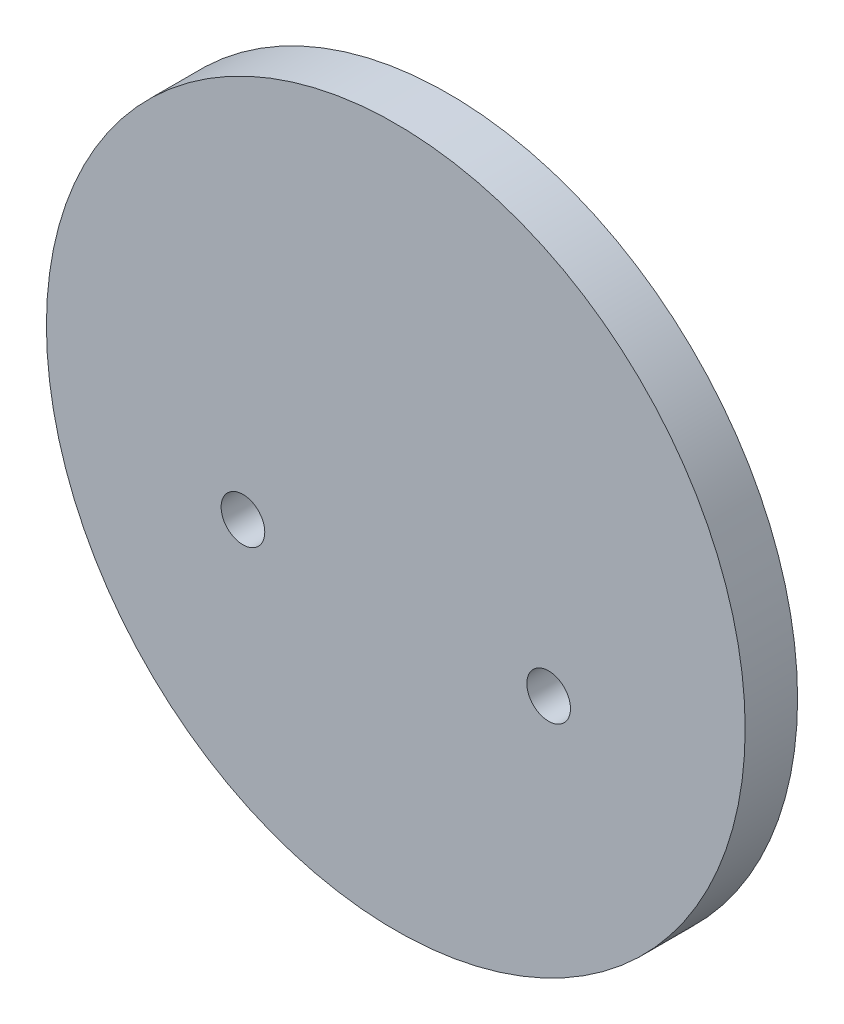
from build123d import *

# Parameters (mm, degrees)
SKETCH3_R           = 40
BOSS_EXTRUDE1_DEPTH = 6
SKETCH4_R           = 2.1
CUT_EXTRUDE1_DEPTH  = 57.885850613
SKETCH5_R           = 5
CUT_EXTRUDE2_DEPTH  = 1.5
MOVE_FACE1_BY       = 0.4
MOVE_FACE1_2_BY     = 0.4


with BuildPart() as part:
    # Sketch3 → Boss-Extrude1 (new body)
    with BuildSketch(Plane.XY):
        Circle(SKETCH3_R)
    extrude(amount=BOSS_EXTRUDE1_DEPTH)

    # Sketch4 → Cut-Extrude1 (cut, through all)
    with BuildSketch(Plane.XY.offset(6)):
        with Locations((-17.5, -8)):
            Circle(SKETCH4_R)
        with Locations((17.5, -8)):
            Circle(SKETCH4_R)
    extrude(amount=-CUT_EXTRUDE1_DEPTH, mode=Mode.SUBTRACT)

    # Sketch5 → Cut-Extrude2 (cut)
    with BuildSketch(Plane(origin=(0, 0, 0), x_dir=(-1, 0, 0), z_dir=(0, 0, -1))):
        with Locations((-17.5, -8)):
            Circle(SKETCH5_R)
        with Locations((17.5, -8)):
            Circle(SKETCH5_R)
    extrude(amount=-CUT_EXTRUDE2_DEPTH, mode=Mode.SUBTRACT)

    # Move Face1: a curved face moved inward by 0.4
    add(Solid.thicken(part.faces().sort_by_distance((-19.6, -8, 3.75))[0], -MOVE_FACE1_BY), mode=Mode.SUBTRACT)

    # Move Face1 2: a curved face moved inward by 0.4
    add(Solid.thicken(part.faces().sort_by_distance((15.4, -8, 3.75))[0], -MOVE_FACE1_2_BY), mode=Mode.SUBTRACT)


solid = part.part
